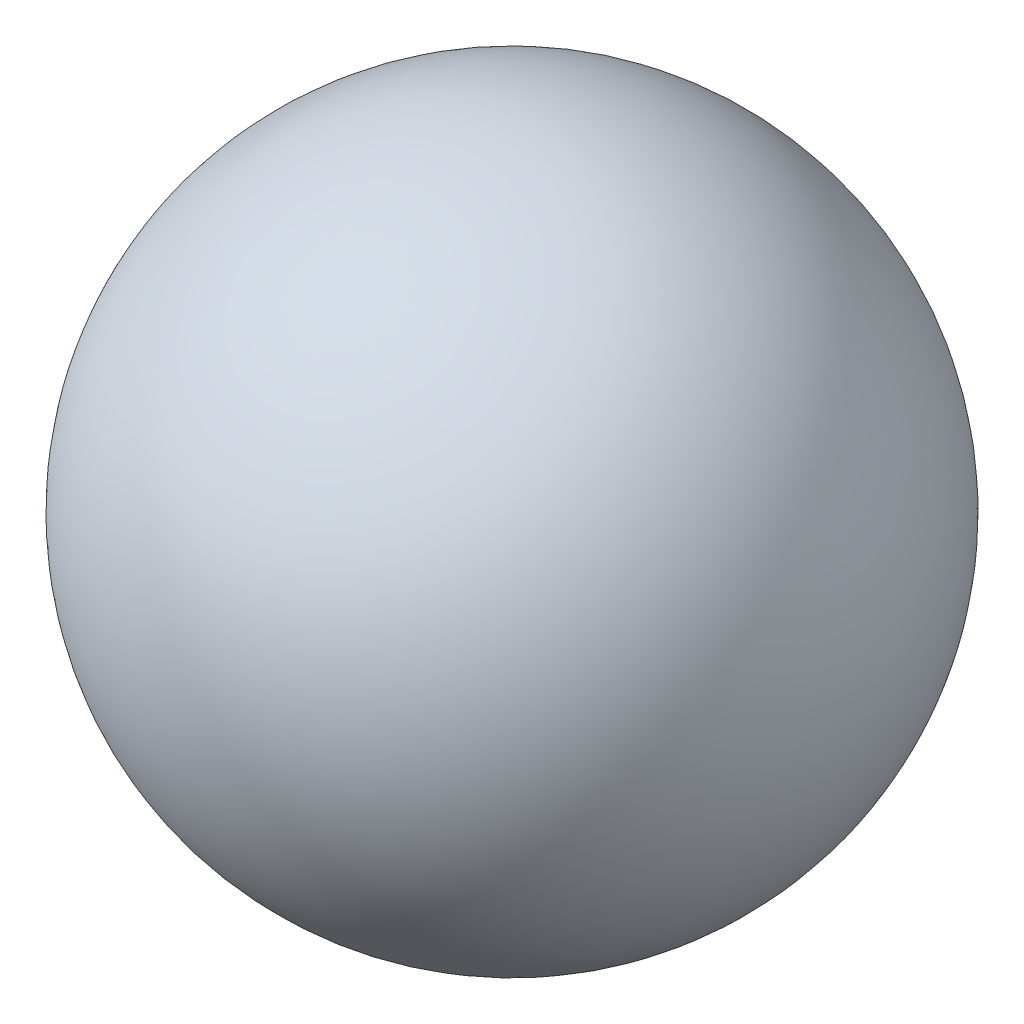
from build123d import *


with BuildPart() as part:
    # Sketch1 → Revolve3 (revolve)
    with BuildSketch(Plane(origin=(0, 0, 0), x_dir=(1, 0, 0), z_dir=(0, 1, 0))):
        with BuildLine():
            Line((-17.5, 0), (17.5, 0))
            ThreePointArc((17.5, 0), (0, -17.5), (-17.5, 0))
        make_face()
    revolve(axis=Axis((-17.5, 0, 0), (1, 0, 0)))


solid = part.part
